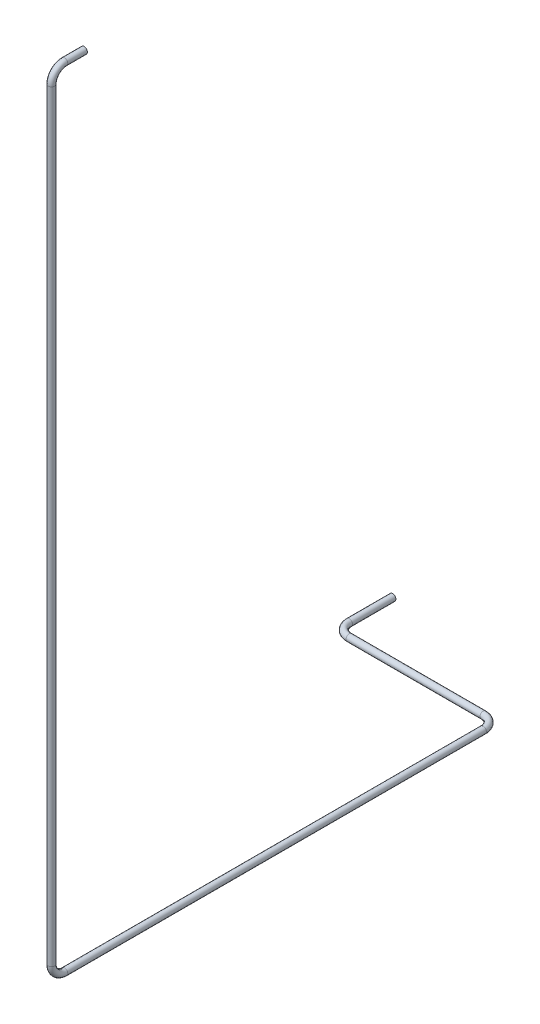
from build123d import *

# Parameters (mm, degrees)
SWEEP_THIN1_PROFILE_R   = 15
SWEEP_THIN1_PROFILE_R_2 = 14


with BuildPart() as part:
    # Sweep-Thin1: sweep along a curve in space
    with BuildLine() as sweep_thin1_path:
        Line((-33126.117683292, -14247.013633934, 43140.470196057), (-33126.117683292, -14247.013633934, 43230.470196057))
        ThreePointArc((-33126.117683292, -14307.013633934, 43290.470196057), (-33126.117683292, -14264.587227063, 43272.896602928), (-33126.117683292, -14247.013633934, 43230.470196057))
        Line((-33126.117683292, -14307.013633934, 43290.470196057), (-33126.117683292, -17802.331772457, 43290.470196057))
        ThreePointArc((-33126.117683292, -17862.331772457, 43230.470196057), (-33126.117683292, -17844.758179328, 43272.896602928), (-33126.117683292, -17802.331772457, 43290.470196057))
        Line((-33126.117683292, -17862.331772457, 43230.470196057), (-33126.117683292, -17862.331772457, 41310.135051864))
        ThreePointArc((-33186.117683292, -17862.331772457, 41250.135051864), (-33143.69127642, -17862.331772457, 41267.708644993), (-33126.117683292, -17862.331772457, 41310.135051864))
        Line((-33186.117683292, -17862.331772457, 41250.135051864), (-33800.378676909, -17862.331772457, 41250.135051864))
        ThreePointArc((-33860.378676909, -17862.331772457, 41190.135051864), (-33842.805083781, -17862.331772457, 41232.561458736), (-33800.378676909, -17862.331772457, 41250.135051864))
        Line((-33860.378676909, -17862.331772457, 41190.135051864), (-33860.378676909, -17862.331772457, 40991.24229028))
    # Sweep-Thin1 profile (on start of the path) → Sweep-Thin1 (sweep)
    with BuildSketch(Plane(origin=(-33126.117683292, -14247.013633934, 43140.470196057), x_dir=(1, 0, 0), z_dir=(0, 0, 1))):
        Circle(SWEEP_THIN1_PROFILE_R)
        Circle(SWEEP_THIN1_PROFILE_R_2, mode=Mode.SUBTRACT)
    sweep(path=sweep_thin1_path.line)


solid = part.part
